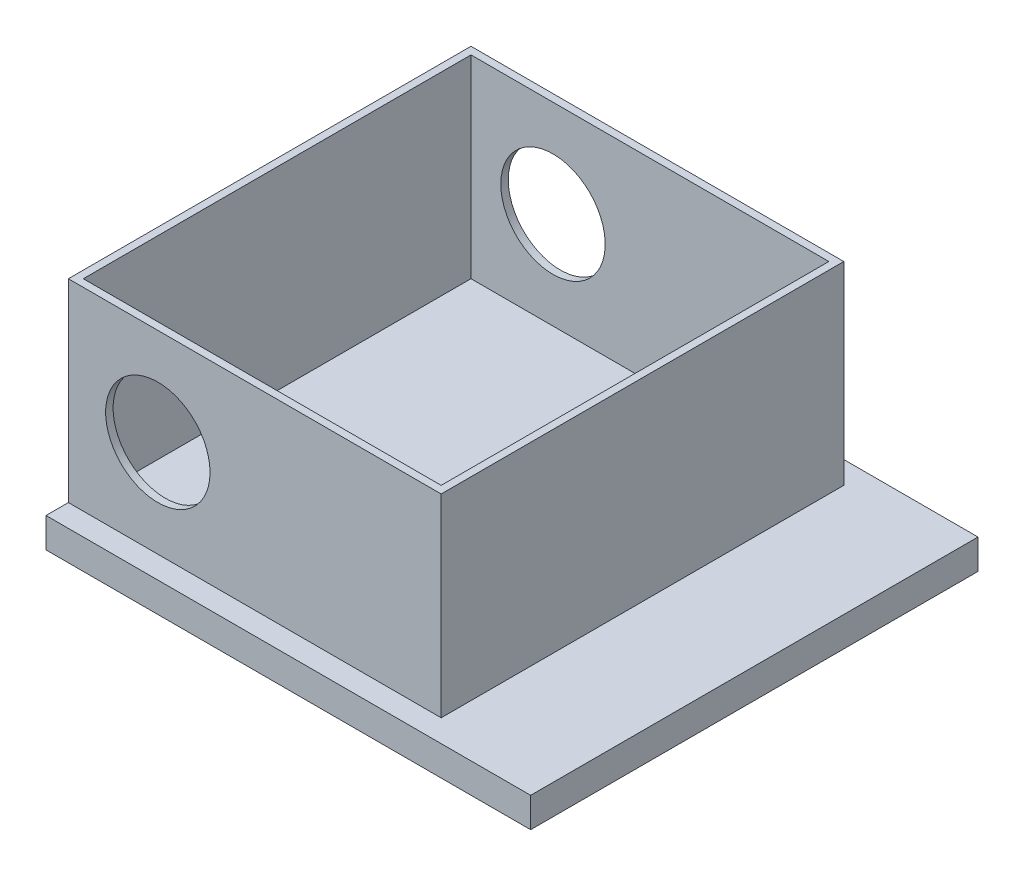
from build123d import *

# Parameters (mm, degrees)
ESQUISSE1_W             = 32.5
ESQUISSE1_H             = 30
BOSS_EXTRU_1_DEPTH      = 2
ESQUISSE1_4_W           = 25
ESQUISSE1_4_H           = 27
ESQUISSE1_4_W_2         = 24
ESQUISSE1_4_H_2         = 26
BOSS_EXTRU_2_DEPTH      = 15
ESQUISSE6_R             = 3.5
ENL_V_MAT_EXTRU_2_DEPTH = 0.5
ENL_V_START             = -0.5
ESQUISSE5_R             = 3.5
ENL_V_MAT_EXTRU_3_DEPTH = 0.5


with BuildPart() as part:
    # Esquisse1 → Boss.-Extru.1 (new body)
    with BuildSketch(Plane(origin=(0, 0, 0), x_dir=(1, 0, 0), z_dir=(0, 1, 0))):
        with Locations((-4.171052632, 10.289473684)):
            Rectangle(ESQUISSE1_W, ESQUISSE1_H)
    extrude(amount=BOSS_EXTRU_1_DEPTH)

    # Esquisse1_4 → Boss.-Extru.2 (add)
    with BuildSketch(Plane(origin=(0, 0, 0), x_dir=(1, 0, 0), z_dir=(0, 1, 0))):
        with Locations((-7.921052632, 10.289473684)):
            Rectangle(ESQUISSE1_4_W, ESQUISSE1_4_H)
        with Locations((-7.921052632, 10.289473684)):
            Rectangle(ESQUISSE1_4_W_2, ESQUISSE1_4_H_2, mode=Mode.SUBTRACT)
    extrude(amount=BOSS_EXTRU_2_DEPTH)

    # Esquisse6 → Enlèv. mat.-Extru.2 (cut)
    with BuildSketch(Plane.XY.offset(3.210526316)):
        with Locations((-14.421052632, 8.5)):
            Circle(ESQUISSE6_R)
    extrude(amount=-ENL_V_MAT_EXTRU_2_DEPTH, mode=Mode.SUBTRACT)

    # Esquisse5 → Enlèv. mat.-Extru.3 (cut)
    with BuildSketch(Plane(origin=(0, 0, -23.789473684), x_dir=(-1, 0, 0), z_dir=(0, 0, -1)).offset(ENL_V_START)):
        with Locations((14.421052632, 8.5)):
            Circle(ESQUISSE5_R)
    extrude(amount=ENL_V_MAT_EXTRU_3_DEPTH, mode=Mode.SUBTRACT)


solid = part.part
